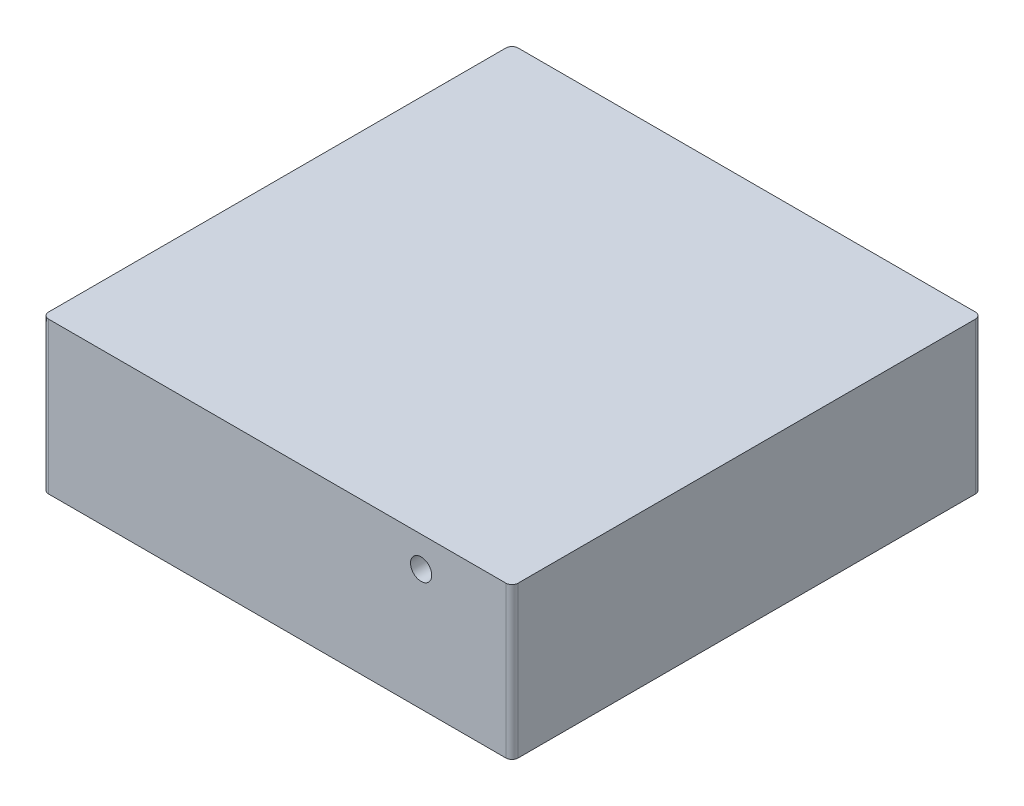
from build123d import *

# Parameters (mm, degrees)
SKETCH1_W             = 77.5
SKETCH1_H             = 77.5
BOSS_EXTRUDE1_DEPTH   = 25
SKETCH2_W             = 70.5
SKETCH2_H             = 70.5
CUT_EXTRUDE1_DEPTH    = 23
SKETCH4_W             = 75.5
SKETCH4_H             = 75.5
SKETCH4_W_2           = 72.5
SKETCH4_H_2           = 72.5
CUT_EXTRUDE3_DEPTH    = 4
BOSS_EXTRUDE2_START   = 2
SKETCH5_R             = 1
BOSS_EXTRUDE2_DEPTH   = 21
BOSS_EXTRUDE2_2_DEPTH = 21
BOSS_EXTRUDE2_3_DEPTH = 21
BOSS_EXTRUDE2_4_DEPTH = 21
SKETCH6_R             = 1.75
CUT_EXTRUDE4_DEPTH    = 7
SKETCH7_R             = 2
CUT_EXTRUDE6_DEPTH    = 3.5
FILLET6_R             = 1
FILLET7_R             = 1
FILLET8_R             = 1
FILLET9_R             = 1


with BuildPart() as part:
    # Sketch1 → Boss-Extrude1 (new body)
    with BuildSketch(Plane(origin=(0, 0, 0), x_dir=(1, 0, 0), z_dir=(0, 1, 0))):
        with Locations((38.75, 38.75)):
            Rectangle(SKETCH1_W, SKETCH1_H)
    extrude(amount=BOSS_EXTRUDE1_DEPTH)

    # Sketch2 → Cut-Extrude1 (cut)
    with BuildSketch(Plane(origin=(0, 0, 0), x_dir=(1, 0, 0), z_dir=(0, 1, 0))):
        with Locations((38.75, 38.75)):
            Rectangle(SKETCH2_W, SKETCH2_H)
    extrude(amount=CUT_EXTRUDE1_DEPTH, mode=Mode.SUBTRACT)

    # Sketch4 → Cut-Extrude3 (cut)
    with BuildSketch(Plane(origin=(0, 0, 0), x_dir=(1, 0, 0), z_dir=(0, 1, 0))):
        with Locations((38.75, 38.75)):
            Rectangle(SKETCH4_W, SKETCH4_H)
        with Locations((38.75, 38.75)):
            Rectangle(SKETCH4_W_2, SKETCH4_H_2, mode=Mode.SUBTRACT)
    extrude(amount=CUT_EXTRUDE3_DEPTH, mode=Mode.SUBTRACT)

    # Sketch6 → Cut-Extrude4 (cut)
    with BuildSketch(Plane.XY):
        with Locations((62.5, 20)):
            Circle(SKETCH6_R)
    extrude(amount=-CUT_EXTRUDE4_DEPTH, mode=Mode.SUBTRACT)

    # Sketch7 → Cut-Extrude6 (cut)
    with BuildSketch(Plane(origin=(0, 0, 0), x_dir=(0, 0, -1), z_dir=(1, 0, 0))):
        with Locations((62.5, 20)):
            Circle(SKETCH7_R)
    extrude(amount=CUT_EXTRUDE6_DEPTH, mode=Mode.SUBTRACT)

    # Fillet6
    fillet6_edges = [part.edges().sort_by_distance(p)[0] for p in [
        (77.5, 12.5, -77.5),
    ]]
    fillet(fillet6_edges, radius=FILLET6_R)

    # Fillet7
    fillet7_edges = [part.edges().sort_by_distance(p)[0] for p in [
        (77.5, 12.5, 0),
    ]]
    fillet(fillet7_edges, radius=FILLET7_R)

    # Fillet8
    fillet8_edges = [part.edges().sort_by_distance(p)[0] for p in [
        (0, 12.5, 0),
    ]]
    fillet(fillet8_edges, radius=FILLET8_R)

    # Fillet9
    fillet9_edges = [part.edges().sort_by_distance(p)[0] for p in [
        (0, 12.5, -77.5),
    ]]
    fillet(fillet9_edges, radius=FILLET9_R)


with BuildPart() as body_2:
    # Sketch5 → Boss-Extrude2 (new body)
    with BuildSketch(Plane(origin=(0, 0, 0), x_dir=(1, 0, 0), z_dir=(0, 1, 0)).offset(BOSS_EXTRUDE2_START)):
        with Locations((10.5, 10.5)):
            Circle(SKETCH5_R)
    extrude(amount=BOSS_EXTRUDE2_DEPTH)


with BuildPart() as body_3:
    # Sketch5 → Boss-Extrude2 2 (new body)
    with BuildSketch(Plane(origin=(0, 0, 0), x_dir=(1, 0, 0), z_dir=(0, 1, 0)).offset(BOSS_EXTRUDE2_START)):
        with Locations((67, 10.5)):
            Circle(SKETCH5_R)
    extrude(amount=BOSS_EXTRUDE2_2_DEPTH)


with BuildPart() as body_4:
    # Sketch5 → Boss-Extrude2 3 (new body)
    with BuildSketch(Plane(origin=(0, 0, 0), x_dir=(1, 0, 0), z_dir=(0, 1, 0)).offset(BOSS_EXTRUDE2_START)):
        with Locations((67, 67)):
            Circle(SKETCH5_R)
    extrude(amount=BOSS_EXTRUDE2_3_DEPTH)


with BuildPart() as body_5:
    # Sketch5 → Boss-Extrude2 4 (new body)
    with BuildSketch(Plane(origin=(0, 0, 0), x_dir=(1, 0, 0), z_dir=(0, 1, 0)).offset(BOSS_EXTRUDE2_START)):
        with Locations((10.5, 67)):
            Circle(SKETCH5_R)
    extrude(amount=BOSS_EXTRUDE2_4_DEPTH)


solid = Compound([part.part, body_2.part, body_3.part, body_4.part, body_5.part])
